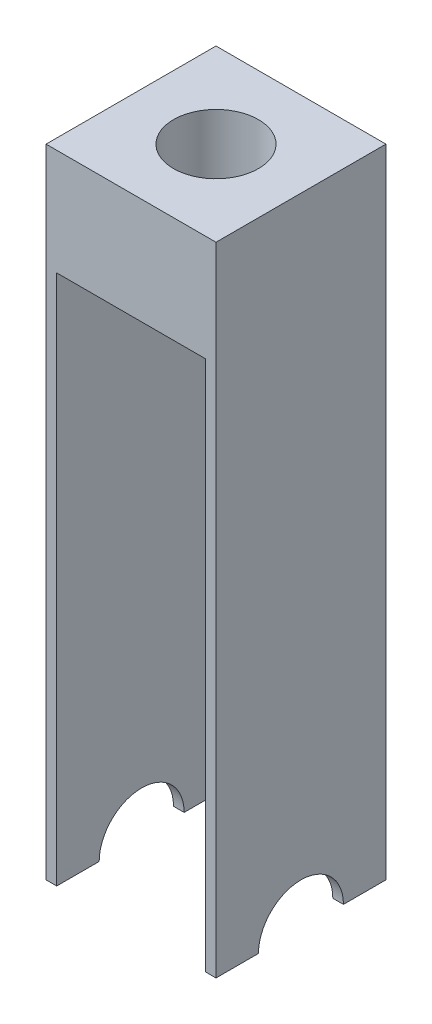
from build123d import *

# Parameters (mm, degrees)
BOSS_EXTRUDE2_DEPTH = 80
SKETCH4_W           = 70
SKETCH4_H           = 250
CUT_EXTRUDE1_DEPTH  = 81
SKETCH5_R           = 20
CUT_EXTRUDE2_DEPTH  = 40


with BuildPart() as part:
    # Sketch1 → Boss-Extrude2 (new body)
    with BuildSketch(Plane(origin=(0, 0, 0), x_dir=(0, 0, -1), z_dir=(1, 0, 0))):
        with BuildLine():
            Line((-20, -150), (-40, -150))
            Line((-40, -150), (-40, 150))
            Line((-40, 150), (40, 150))
            Line((40, 150), (40, -150))
            Line((40, -150), (20, -150))
            ThreePointArc((20, -150), (0, -130), (-20, -150))
        make_face()
    extrude(amount=BOSS_EXTRUDE2_DEPTH)

    # Sketch4 → Cut-Extrude1 (cut, through all)
    with BuildSketch(Plane.XY.offset(40)):
        with Locations((40, -25)):
            Rectangle(SKETCH4_W, SKETCH4_H)
    extrude(amount=-CUT_EXTRUDE1_DEPTH, mode=Mode.SUBTRACT)

    # Sketch5 → Cut-Extrude2 (cut)
    with BuildSketch(Plane(origin=(0, 150, 0), x_dir=(1, 0, 0), z_dir=(0, 1, 0))):
        with Locations((40, 0)):
            Circle(SKETCH5_R)
    extrude(amount=-CUT_EXTRUDE2_DEPTH, mode=Mode.SUBTRACT)


solid = part.part
